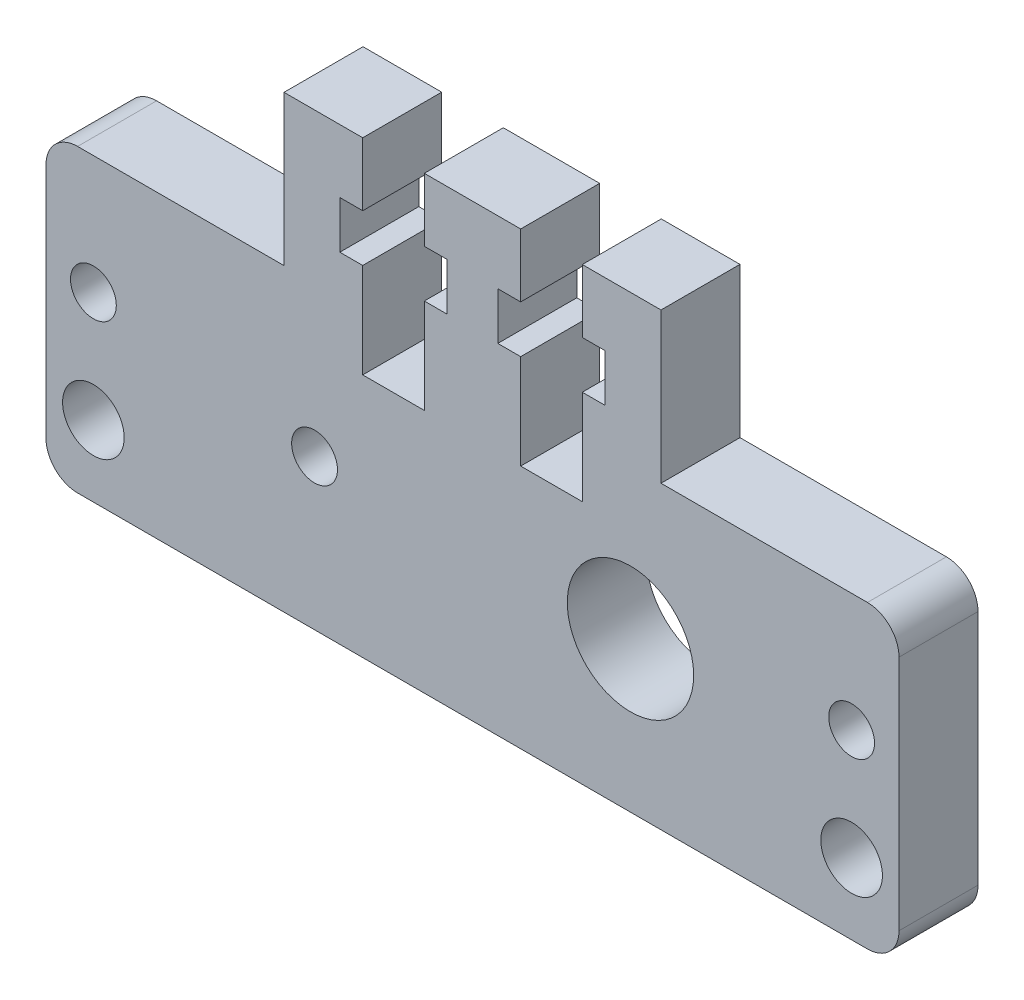
from build123d import *

# Parameters (mm, degrees)
SKETCH1_R           = 1.95
SKETCH1_R_2         = 4
SKETCH1_R_3         = 1.45
BOSS_EXTRUDE1_DEPTH = 5


with BuildPart() as part:
    # Sketch1 → Boss-Extrude1 (new body)
    with BuildSketch(Plane.XY.offset(-5.551615438)):
        with BuildLine():
            Line((-25.464626351, 10.13731735), (-12.396849296, 10.13731735))
            Line((-12.396849296, 10.13731735), (-12.396849296, 19.63731735))
            Line((-12.396849296, 19.63731735), (-7.414626351, 19.63731735))
            Line((-7.414626351, 19.63731735), (-7.414626351, 15.63731735))
            Line((-7.414626351, 15.63731735), (-8.864626351, 15.63731735))
            Line((-8.864626351, 15.63731735), (-8.864626351, 12.63731735))
            Line((-8.864626351, 12.63731735), (-7.414626351, 12.63731735))
            Line((-7.414626351, 12.63731735), (-7.414626351, 6.63731735))
            Line((-7.414626351, 6.63731735), (-3.514626351, 6.63731735))
            Line((-3.514626351, 6.63731735), (-3.514626351, 12.63731735))
            Line((-3.514626351, 12.63731735), (-2.064626351, 12.63731735))
            Line((-2.064626351, 12.63731735), (-2.064626351, 15.63731735))
            Line((-2.064626351, 15.63731735), (-3.514626351, 15.63731735))
            Line((-3.514626351, 15.63731735), (-3.514626351, 19.63731735))
            Line((-3.514626351, 19.63731735), (2.585373649, 19.63731735))
            Line((2.585373649, 19.63731735), (2.585373649, 15.63731735))
            Line((2.585373649, 15.63731735), (1.135373649, 15.63731735))
            Line((1.135373649, 15.63731735), (1.135373649, 12.63731735))
            Line((1.135373649, 12.63731735), (2.585373649, 12.63731735))
            Line((2.585373649, 12.63731735), (2.585373649, 6.63731735))
            Line((2.585373649, 6.63731735), (6.485373649, 6.63731735))
            Line((6.485373649, 6.63731735), (6.485373649, 12.63731735))
            Line((6.485373649, 12.63731735), (7.935373649, 12.63731735))
            Line((7.935373649, 12.63731735), (7.935373649, 15.63731735))
            Line((7.935373649, 15.63731735), (6.485373649, 15.63731735))
            Line((6.485373649, 15.63731735), (6.485373649, 19.63731735))
            Line((6.485373649, 19.63731735), (11.467596593, 19.63731735))
            Line((11.467596593, 19.63731735), (11.467596593, 10.13731735))
            Line((11.467596593, 10.13731735), (24.535373649, 10.13731735))
            ThreePointArc((24.535373649, 10.13731735), (25.949587211, 9.551530913), (26.535373649, 8.13731735))
            Line((26.535373649, 8.13731735), (26.535373649, -6.86268265))
            ThreePointArc((26.535373649, -6.86268265), (25.949587211, -8.276896212), (24.535373649, -8.86268265))
            Line((24.535373649, -8.86268265), (-10, -8.86268265))
            Line((-10, -8.86268265), (-25.464626351, -8.86268265))
            ThreePointArc((-25.464626351, -8.86268265), (-26.878839913, -8.276896212), (-27.464626351, -6.86268265))
            Line((-27.464626351, -6.86268265), (-27.464626351, 8.13731735))
            ThreePointArc((-27.464626351, 8.13731735), (-26.878839913, 9.551530913), (-25.464626351, 10.13731735))
        make_face()
        with Locations((-24.464626351, -4.36268265)):
            Circle(SKETCH1_R, mode=Mode.SUBTRACT)
        with Locations((23.535373649, -4.36268265)):
            Circle(SKETCH1_R, mode=Mode.SUBTRACT)
        with Locations((9.535373649, 0.63731735)):
            Circle(SKETCH1_R_2, mode=Mode.SUBTRACT)
        with Locations((-10.464626351, 0.63731735)):
            Circle(SKETCH1_R_3, mode=Mode.SUBTRACT)
        with Locations((-24.464626351, 2.63731735)):
            Circle(SKETCH1_R_3, mode=Mode.SUBTRACT)
        with Locations((23.535373649, 2.63731735)):
            Circle(SKETCH1_R_3, mode=Mode.SUBTRACT)
    extrude(amount=BOSS_EXTRUDE1_DEPTH)


solid = part.part
